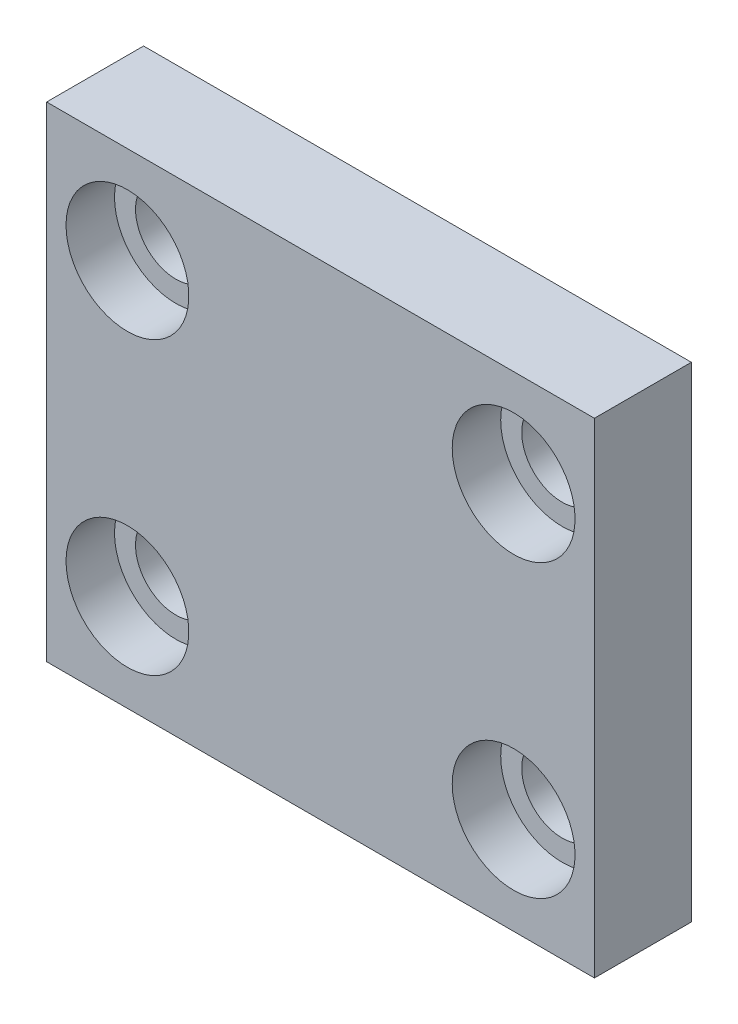
from build123d import *

# Parameters (mm, degrees)
SKETCH1_W           = 33.9
SKETCH1_H           = 30
BOSS_EXTRUDE5_DEPTH = 3
SKETCH3_R           = 2.5
CUT_EXTRUDE2_DEPTH  = 3
SKETCH7_W           = 33.9
SKETCH7_H           = 30
BOSS_EXTRUDE6_DEPTH = 3
SKETCH8_R           = 3.8
CUT_EXTRUDE3_DEPTH  = 3
SKETCH10_R          = 3.8
CUT_EXTRUDE4_DEPTH  = 3


with BuildPart() as part:
    # Sketch1 → Boss-Extrude5 (new body)
    with BuildSketch(Plane.XY):
        Rectangle(SKETCH1_W, SKETCH1_H)
    extrude(amount=BOSS_EXTRUDE5_DEPTH)

    # Sketch3 → Cut-Extrude2 (cut)
    with BuildSketch(Plane.XY.offset(3)):
        with Locations((-11.95, 9)):
            Circle(SKETCH3_R)
        with Locations((11.95, 9)):
            Circle(SKETCH3_R)
        with Locations((11.95, -9)):
            Circle(SKETCH3_R)
        with Locations((-11.95, -9)):
            Circle(SKETCH3_R)
    extrude(amount=-CUT_EXTRUDE2_DEPTH, mode=Mode.SUBTRACT)

    # Sketch7 → Boss-Extrude6 (add)
    with BuildSketch(Plane.XY.offset(3)):
        Rectangle(SKETCH7_W, SKETCH7_H)
    extrude(amount=BOSS_EXTRUDE6_DEPTH)

    # Sketch8 → Cut-Extrude3 (cut)
    with BuildSketch(Plane(origin=(0, 0, 3), x_dir=(-1, 0, 0), z_dir=(0, 0, -1))):
        with Locations((11.95, 9)):
            Circle(SKETCH8_R)
    extrude(amount=-CUT_EXTRUDE3_DEPTH, mode=Mode.SUBTRACT)

    # Sketch10 → Cut-Extrude4 (cut)
    with BuildSketch(Plane(origin=(0, 0, 3), x_dir=(-1, 0, 0), z_dir=(0, 0, -1))):
        with Locations((-11.95, 9)):
            Circle(SKETCH10_R)
        with Locations((-11.95, -9)):
            Circle(SKETCH10_R)
        with Locations((11.95, -9)):
            Circle(SKETCH10_R)
    extrude(amount=-CUT_EXTRUDE4_DEPTH, mode=Mode.SUBTRACT)


solid = part.part
